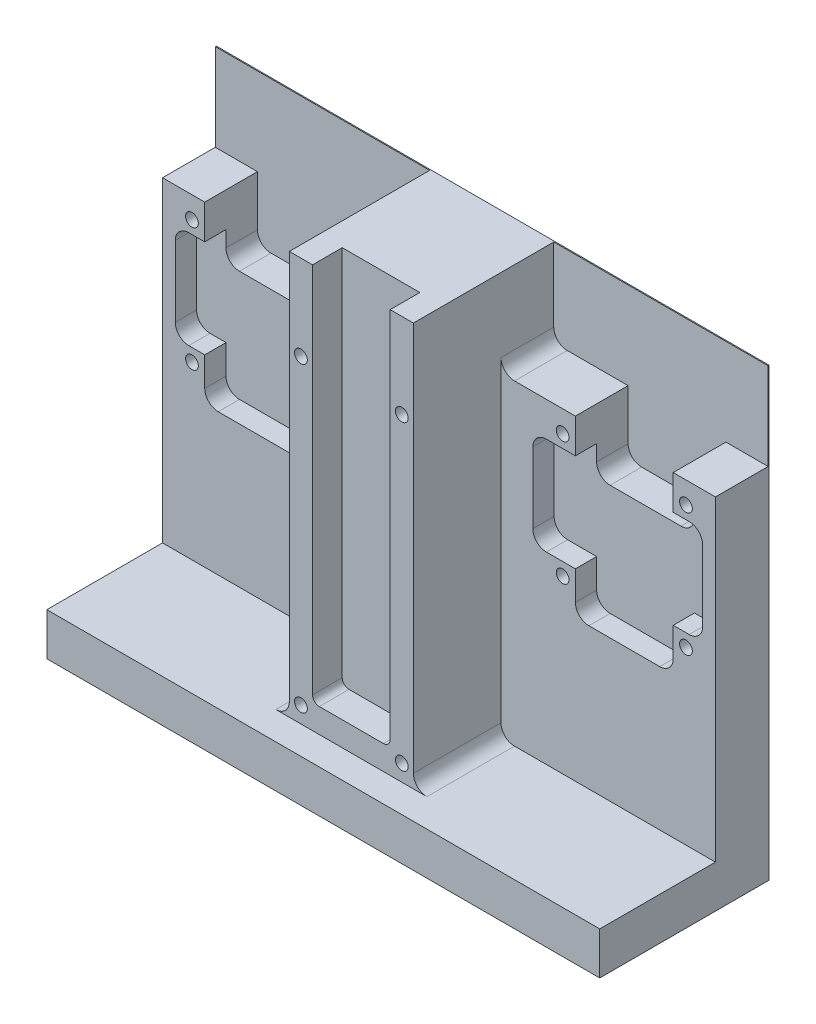
from build123d import *

# Parameters (mm, degrees)
SKETCH1_W           = 130
SKETCH1_H           = 104.86
BOSS_EXTRUDE1_DEPTH = 39.84
SKETCH2_W           = 130
SKETCH2_H           = 94.86
CUT_EXTRUDE1_DEPTH  = 6.6
SKETCH3_W           = 18.25
SKETCH3_H           = 89.15
CUT_EXTRUDE2_DEPTH  = 6.98
SKETCH5_W           = 50.415
SKETCH5_H           = 94.86
CUT_EXTRUDE3_DEPTH  = 20.6
SKETCH6_R           = 1.5
CUT_EXTRUDE4_DEPTH  = 12.4
SKETCH7_W           = 50.415
SKETCH7_H           = 20.5
CUT_EXTRUDE5_DEPTH  = 12.4
SKETCH9_W           = 23
SKETCH9_H           = 15
CUT_EXTRUDE7_DEPTH  = 12.4
CUT_EXTRUDE8_DEPTH  = 5
SKETCH11_R          = 1.5
CUT_EXTRUDE9_DEPTH  = 15
FILLET2_R           = 3.175
FILLET3_R           = 3.175
FILLET4_R           = 3.175
FILLET5_R           = 1.5875
FILLET6_R           = 3.175


with BuildPart() as part:
    # Sketch1 → Boss-Extrude1 (new body)
    with BuildSketch(Plane.XY):
        with Locations((65, -52.43)):
            Rectangle(SKETCH1_W, SKETCH1_H)
    extrude(amount=BOSS_EXTRUDE1_DEPTH)

    # Sketch2 → Cut-Extrude1 (cut)
    with BuildSketch(Plane.XY.offset(39.84)):
        with Locations((65, -47.43)):
            Rectangle(SKETCH2_W, SKETCH2_H)
    extrude(amount=-CUT_EXTRUDE1_DEPTH, mode=Mode.SUBTRACT)

    # Sketch3 → Cut-Extrude2 (cut)
    with BuildSketch(Plane.XY.offset(33.24)):
        with Locations((65, -44.575)):
            Rectangle(SKETCH3_W, SKETCH3_H)
    extrude(amount=-CUT_EXTRUDE2_DEPTH, mode=Mode.SUBTRACT)

    # Sketch5 → Cut-Extrude3 (cut)
    with BuildSketch(Plane.XY.offset(33.24)):
        with Locations((104.7925, -47.43)):
            Rectangle(SKETCH5_W, SKETCH5_H)
        with Locations((25.2075, -47.43)):
            Rectangle(SKETCH5_W, SKETCH5_H)
    extrude(amount=-CUT_EXTRUDE3_DEPTH, mode=Mode.SUBTRACT)

    # Sketch6 → Cut-Extrude4 (cut)
    with BuildSketch(Plane.XY.offset(12.64)):
        with Locations((35.925, -25.6)):
            Circle(SKETCH6_R)
        with Locations((6.925, -25.6)):
            Circle(SKETCH6_R)
        with Locations((35.925, -54.6)):
            Circle(SKETCH6_R)
        with Locations((6.925, -54.6)):
            Circle(SKETCH6_R)
        with Locations((94.075, -25.6)):
            Circle(SKETCH6_R)
        with Locations((123.075, -25.6)):
            Circle(SKETCH6_R)
        with Locations((94.075, -54.6)):
            Circle(SKETCH6_R)
        with Locations((123.075, -54.6)):
            Circle(SKETCH6_R)
    extrude(amount=-CUT_EXTRUDE4_DEPTH, mode=Mode.SUBTRACT)

    # Sketch7 → Cut-Extrude5 (cut)
    with BuildSketch(Plane.XY.offset(12.64)):
        with Locations((25.2075, -10.25)):
            Rectangle(SKETCH7_W, SKETCH7_H)
        with Locations((104.7925, -10.25)):
            Rectangle(SKETCH7_W, SKETCH7_H)
    extrude(amount=-CUT_EXTRUDE5_DEPTH, mode=Mode.SUBTRACT)

    # Sketch9 → Cut-Extrude7 (cut)
    with BuildSketch(Plane.XY.offset(12.64)):
        with Locations((108.575, -28)):
            Rectangle(SKETCH9_W, SKETCH9_H)
        with Locations((21.425, -28)):
            Rectangle(SKETCH9_W, SKETCH9_H)
    extrude(amount=-CUT_EXTRUDE7_DEPTH, mode=Mode.SUBTRACT)

    # Sketch10 → Cut-Extrude8 (cut)
    with BuildSketch(Plane.XY.offset(12.64)):
        Polygon((9.925, -28.6), (3, -28.6), (3, -51.6), (9.925, -51.6), (9.925, -61.6), (32.925, -61.6), (32.925, -51.6), (42.925, -51.6), (42.925, -28.6), (32.925, -28.6), (32.925, -35.5), (9.925, -35.5), align=None)
        Polygon((97.075, -28.6), (87.075, -28.6), (87.075, -51.6), (97.075, -51.6), (97.075, -61.6), (120.075, -61.6), (120.075, -51.6), (127, -51.6), (127, -28.6), (120.075, -28.6), (120.075, -35.5), (97.075, -35.5), align=None)
    extrude(amount=-CUT_EXTRUDE8_DEPTH, mode=Mode.SUBTRACT)

    # Sketch11 → Cut-Extrude9 (cut)
    with BuildSketch(Plane.XY.offset(33.24)):
        with Locations((53.145, -20)):
            Circle(SKETCH11_R)
        with Locations((76.855, -20)):
            Circle(SKETCH11_R)
        with Locations((53.145, -91)):
            Circle(SKETCH11_R)
        with Locations((76.855, -91)):
            Circle(SKETCH11_R)
    extrude(amount=-CUT_EXTRUDE9_DEPTH, mode=Mode.SUBTRACT)

    # Fillet2
    fillet2_edges = [part.edges().sort_by_distance(p)[0] for p in [
        (3, -51.6, 10.14),
    ]]
    fillet(fillet2_edges, radius=FILLET2_R)

    # Fillet3
    fillet3_edges = [part.edges().sort_by_distance(p)[0] for p in [
        (50.415, -20.5, 6.44),
        (79.585, -20.5, 6.44),
        (32.925, -35.5, 3.94),
        (9.925, -35.5, 3.94),
        (42.925, -28.6, 10.14),
        (42.925, -51.6, 10.14),
        (32.925, -61.6, 10.14),
        (9.925, -61.6, 10.14),
        (3, -28.6, 10.14),
        (127, -28.6, 10.14),
        (127, -51.6, 10.14),
        (120.075, -61.6, 10.14),
        (97.075, -61.6, 10.14),
        (87.075, -51.6, 10.14),
        (87.075, -28.6, 10.14),
    ]]
    fillet(fillet3_edges, radius=FILLET3_R)

    # Fillet4
    fillet4_edges = [part.edges().sort_by_distance(p)[0] for p in [
        (120.075, -35.5, 3.94),
        (97.075, -35.5, 3.94),
    ]]
    fillet(fillet4_edges, radius=FILLET4_R)

    # Fillet5
    fillet5_edges = [part.edges().sort_by_distance(p)[0] for p in [
        (74.125, -89.15, 29.75),
        (55.875, -89.15, 29.75),
    ]]
    fillet(fillet5_edges, radius=FILLET5_R)

    # Fillet6
    fillet6_edges = [part.edges().sort_by_distance(p)[0] for p in [
        (79.585, -94.86, 22.94),
        (50.415, -94.86, 22.94),
    ]]
    fillet(fillet6_edges, radius=FILLET6_R)


solid = part.part
